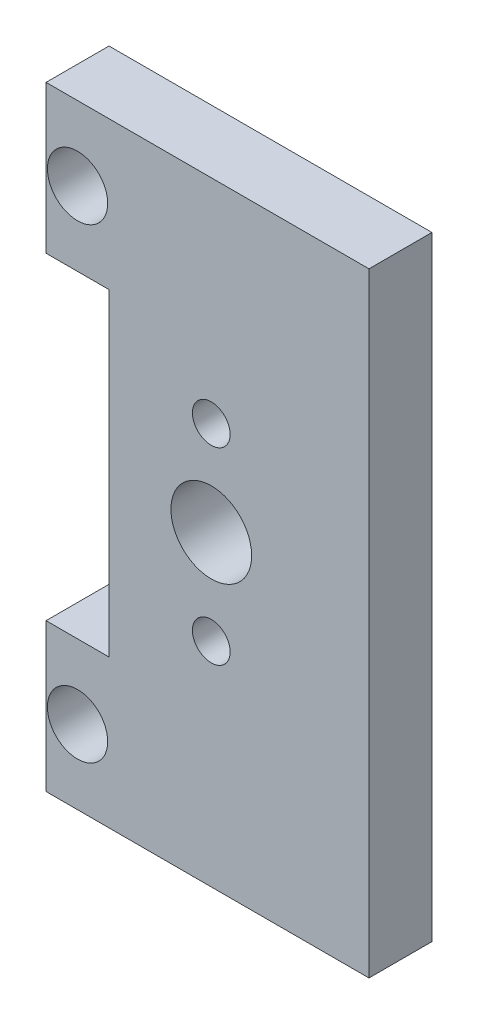
from build123d import *

# Parameters (mm, degrees)
SKETCH2_R           = 1.4224
SKETCH2_R_2         = 0.889
SKETCH2_R_3         = 1.905
BOSS_EXTRUDE1_DEPTH = 2.9718


with BuildPart() as part:
    # Sketch2 → Boss-Extrude1 (new body)
    with BuildSketch(Plane.XY):
        Polygon((0, 6.985), (0, 0), (15.24, 0), (15.24, 28.985), (0, 28.985), (0, 22), (2.9718, 22), (2.9718, 6.985), align=None)
        with Locations((1.4859, 3.4925)):
            Circle(SKETCH2_R, mode=Mode.SUBTRACT)
        with Locations((7.7978, 10.0475)):
            Circle(SKETCH2_R_2, mode=Mode.SUBTRACT)
        with Locations((7.7978, 14.4925)):
            Circle(SKETCH2_R_3, mode=Mode.SUBTRACT)
        with Locations((1.4859, 25.4925)):
            Circle(SKETCH2_R, mode=Mode.SUBTRACT)
        with Locations((7.7978, 18.9375)):
            Circle(SKETCH2_R_2, mode=Mode.SUBTRACT)
    extrude(amount=BOSS_EXTRUDE1_DEPTH)


solid = part.part
